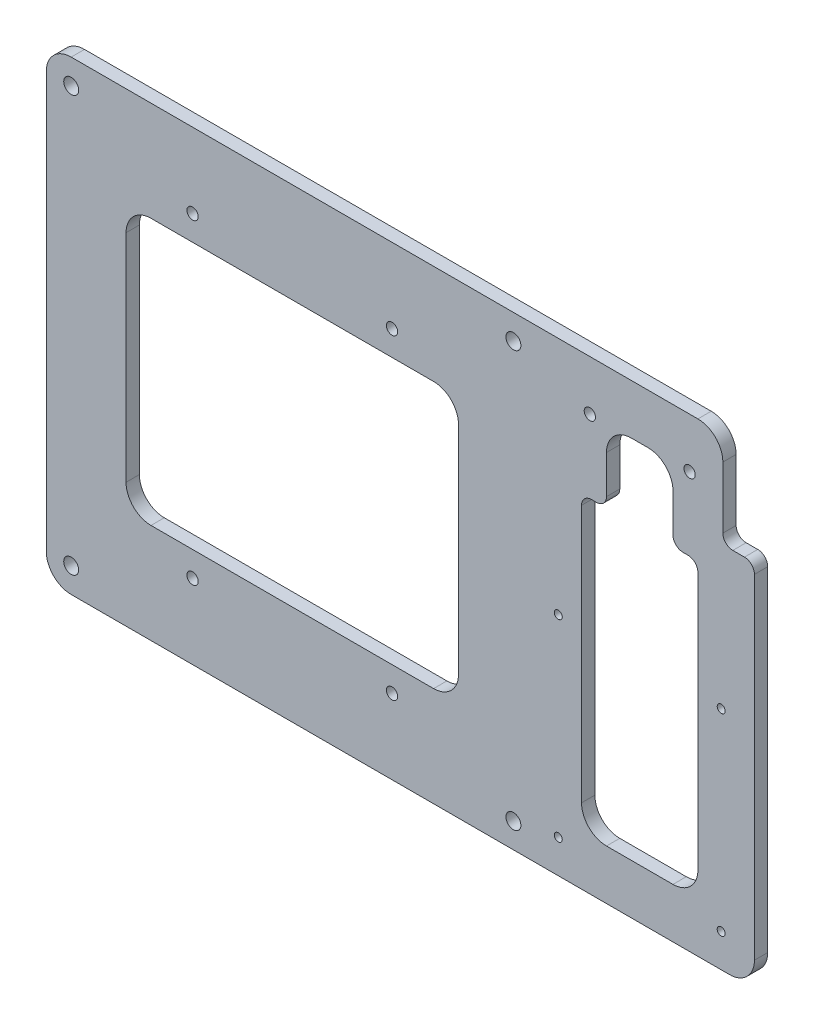
from build123d import *

# Parameters (mm, degrees)
SKETCH_1_W          = 140
SKETCH_1_H          = 148
EXTRUDE_1_DEPTH     = 4
HOLE_WIZARD_M4_1_D  = 4.5
HOLE_WIZARD_M3_2_D  = 3.4
SKETCH_9_W          = 65
SKETCH_9_H          = 140
EXTRUDE_3_DEPTH     = 4
HOLE_WIZARD_M2_1_D  = 2.4
SKETCH_13_W         = 9.5
SKETCH_13_H         = 29
CUT_EXTRUDE_1_DEPTH = 5
HOLE_WIZARD_M3_1_D  = 3.4
FILLET_12_R         = 7.5
FILLET_11_R         = 3


with BuildPart() as part:
    # ｽｹｯﾁ1 → ﾎﾞｽ - 押し出し1 (new body)
    with BuildSketch(Plane(origin=(0, 0, 0), x_dir=(0, 1, 0), z_dir=(0, 0, 1))):
        with Locations((70, -74)):
            Rectangle(SKETCH_1_W, SKETCH_1_H)
        Polygon((110, -124), (30, -124), (30, -74), (30, -24), (110, -24), align=None, mode=Mode.SUBTRACT)
    extrude(amount=EXTRUDE_1_DEPTH)

    # M4 すきま穴1 (through all)
    with Locations(Plane.XY.offset(4)):
        with Locations((7.5, 132.5), (140.5, 132.5), (7.5, 7.5), (140.5, 7.5)):
            Hole(HOLE_WIZARD_M4_1_D / 2)

    # M3 すきま穴2 (through all)
    with Locations(Plane.XY.offset(4)):
        with Locations((44, 117.5), (104, 117.5), (104, 22.5), (44, 22.5)):
            Hole(HOLE_WIZARD_M3_2_D / 2)

    # ｽｹｯﾁ9 → ﾎﾞｽ - 押し出し3 (add)
    with BuildSketch(Plane.XY.offset(4)):
        with Locations((180.5, 70)):
            Rectangle(SKETCH_9_W, SKETCH_9_H)
    extrude(amount=-EXTRUDE_3_DEPTH)

    # M2 すきま穴1 (through all)
    with Locations(Plane.XY.offset(4)):
        with Locations((203, 10), (154, 68), (203, 68), (154, 10)):
            Hole(HOLE_WIZARD_M2_1_D / 2)

    # ｽｹｯﾁ13 → ｶｯﾄ - 押し出し1 (cut, through all)
    with BuildSketch(Plane.XY.offset(4)):
        Polygon((168.5, 125), (188.5, 125), (188.5, 103), (196, 103), (196, 15), (161, 15), (161, 103), (168.5, 103), align=None)
        with Locations((208.25, 125.5)):
            Rectangle(SKETCH_13_W, SKETCH_13_H)
    extrude(amount=-CUT_EXTRUDE_1_DEPTH, mode=Mode.SUBTRACT)

    # M3 すきま穴1 (through all)
    with Locations(Plane.XY.offset(4)):
        with Locations((163.5, 125), (193.5, 125)):
            Hole(HOLE_WIZARD_M3_1_D / 2)

    # ﾌｨﾚｯﾄ12
    fillet_12_edges = [part.edges().sort_by_distance(p)[0] for p in [
        (168.5, 125, 2),
        (188.5, 125, 2),
        (196, 15, 2),
        (161, 15, 2),
        (203.5, 140, 2),
        (24, 30, 2),
        (124, 30, 2),
        (124, 110, 2),
        (24, 110, 2),
        (213, 0, 2),
        (0, 0, 2),
        (0, 140, 2),
    ]]
    fillet(fillet_12_edges, radius=FILLET_12_R)

    # ﾌｨﾚｯﾄ11
    fillet_11_edges = [part.edges().sort_by_distance(p)[0] for p in [
        (168.5, 103, 2),
        (188.5, 103, 2),
        (196, 103, 2),
        (161, 103, 2),
        (213, 111, 2),
        (203.5, 111, 2),
    ]]
    fillet(fillet_11_edges, radius=FILLET_11_R)


solid = part.part
